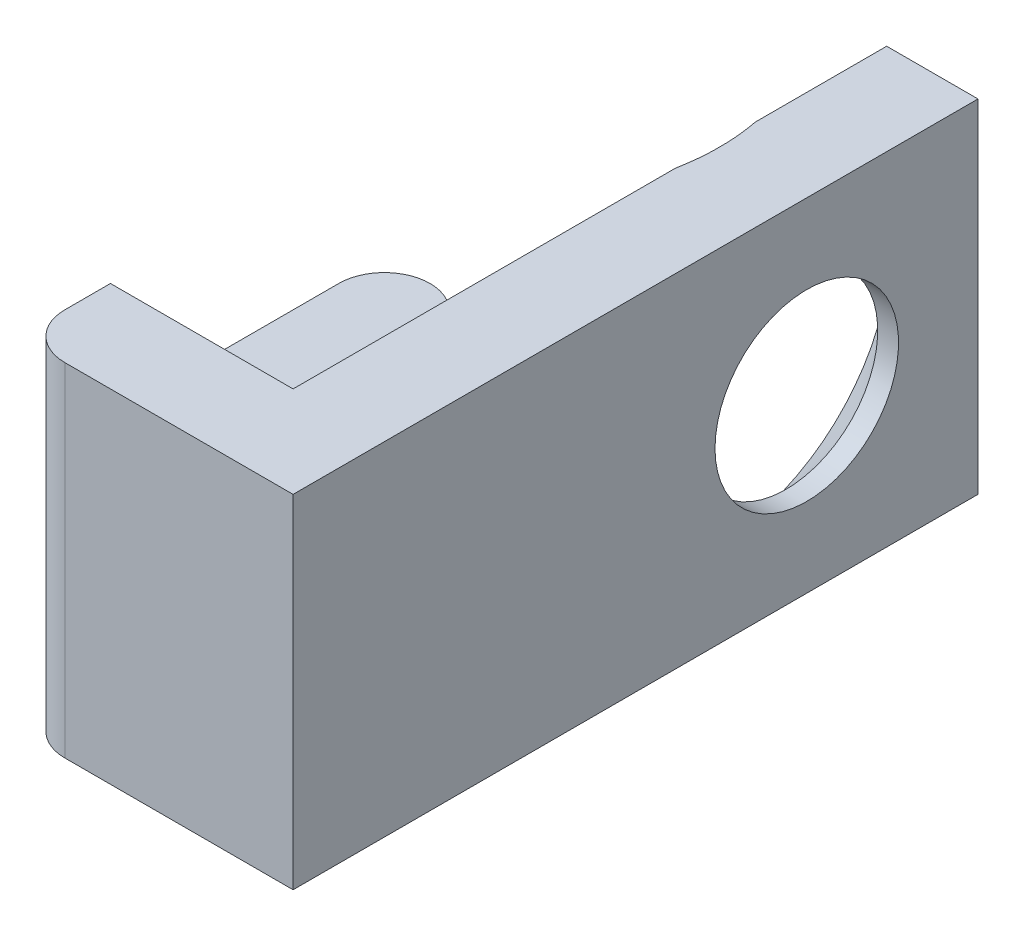
from build123d import *

# Parameters (mm, degrees)
BOSS_EXTRUDE1_DEPTH = 4.7625
CUT_EXTRUDE1_START  = -1.27
CUT_EXTRUDE1_DEPTH  = 6.08


with BuildPart() as part:
    # Sketch1 → Boss-Extrude1 (new body, symmetric)
    with BuildSketch(Plane(origin=(0, 0, 0), x_dir=(1, 0, 0), z_dir=(0, 1, 0))):
        with BuildLine():
            Line((-5.08, -6.985), (-3.81, -6.985))
            Line((-3.81, -6.985), (-3.81, -0.635))
            ThreePointArc((-3.81, -0.635), (-5.08, 0.635), (-6.35, -0.635))
            Line((-6.35, -0.635), (-6.35, -8.255))
            ThreePointArc((-6.35, -8.255), (-5.978025612, -7.356974388), (-5.08, -6.985))
        make_face()
        with BuildLine():
            ThreePointArc((-6.35, -8.255), (-5.978025612, -9.153025612), (-5.08, -9.525))
            ThreePointArc((-5.08, -9.525), (-4.181974388, -9.153025612), (-3.81, -8.255))
            Line((-3.81, -8.255), (-3.81, -6.985))
            Line((-3.81, -6.985), (-5.08, -6.985))
            ThreePointArc((-5.08, -6.985), (-5.978025612, -7.356974388), (-6.35, -8.255))
        make_face()
        with BuildLine():
            Line((-5.08, -9.525), (-1.27, -9.525))
            Line((-1.27, -9.525), (-1.27, -6.985))
            Line((-1.27, -6.985), (-3.81, -6.985))
            Line((-3.81, -6.985), (-3.81, -8.255))
            ThreePointArc((-3.81, -8.255), (-4.181974388, -9.153025612), (-5.08, -9.525))
        make_face()
        with BuildLine():
            Line((-1.27, -6.985), (-1.27, -9.525))
            ThreePointArc((-1.27, -9.525), (0, -8.255), (-1.27, -6.985))
        make_face()
        with BuildLine():
            ThreePointArc((-1.27, -6.985), (0, -8.255), (-1.27, -9.525))
            Line((-1.27, -9.525), (1.27, -9.525))
            Line((1.27, -9.525), (1.27, 9.525))
            Line((1.27, 9.525), (-1.27, 9.525))
            Line((-1.27, 9.525), (-1.27, -6.985))
        make_face()
    extrude(amount=BOSS_EXTRUDE1_DEPTH, both=True)

    # Sketch3 → CSK for #10 Flat Head Machine Screw (100)1 (revolve, cut)
    with BuildSketch(Plane(origin=(-1.27, 0, -4.7625), x_dir=(0, 0, 1), z_dir=(0, 1, 0))):
        Polygon((0, 0), (0, 2.54), (2.5527, 2.54), (2.5527, 1.960808018), (4.8895, 0), align=None)
    revolve(axis=Axis((-7.62, 0, -4.7625), (1, 0, 0)), mode=Mode.SUBTRACT)

    # Sketch4 → Cut-Extrude1 (cut, through all)
    with BuildSketch(Plane(origin=(0, 0, 0), x_dir=(0, 0, -1), z_dir=(1, 0, 0)).offset(CUT_EXTRUDE1_START)):
        with BuildLine():
            Line((0.635, -7.9375), (-3.81, -7.9375))
            ThreePointArc((-3.81, -7.9375), (-6.985, -4.7625), (-3.81, -1.5875))
            Line((-3.81, -1.5875), (0.635, -1.5875))
            ThreePointArc((0.635, -1.5875), (3.81, -4.7625), (0.635, -7.9375))
        make_face()
        with BuildLine():
            Line((0.635, 1.5875), (-3.81, 1.5875))
            ThreePointArc((-3.81, 1.5875), (-6.985, 4.7625), (-3.81, 7.9375))
            Line((-3.81, 7.9375), (0.635, 7.9375))
            ThreePointArc((0.635, 7.9375), (3.81, 4.7625), (0.635, 1.5875))
        make_face()
    extrude(amount=-CUT_EXTRUDE1_DEPTH, mode=Mode.SUBTRACT)


solid = part.part
